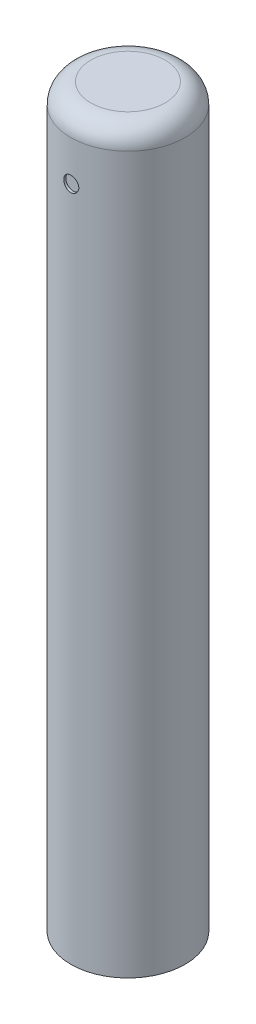
from build123d import *

# Parameters (mm, degrees)
SKETCH1_R           = 14.5
BOSS_EXTRUDE1_DEPTH = 186.69
FILLET1_R           = 5.08
SKETCH5_R           = 1.905
CUT_EXTRUDE4_DEPTH  = 0.635
SKETCH2_R           = 1.905
CUT_EXTRUDE5_DEPTH  = 0.635


with BuildPart() as part:
    # Sketch1 → Boss-Extrude1 (new body)
    with BuildSketch(Plane(origin=(0, 0, 0), x_dir=(1, 0, 0), z_dir=(0, 1, 0))):
        Circle(SKETCH1_R)
    extrude(amount=BOSS_EXTRUDE1_DEPTH)

    # Fillet1
    fillet1_edges = [part.edges().sort_by_distance(p)[0] for p in [
        (-14.5, 186.69, 0),
    ]]
    fillet(fillet1_edges, radius=FILLET1_R)

    # Sketch5 → Cut-Extrude4 (cut)
    with BuildSketch(Plane.XY.offset(-14.499999956)):
        with Locations((0, 171.45)):
            Circle(SKETCH5_R)
    extrude(amount=CUT_EXTRUDE4_DEPTH, mode=Mode.SUBTRACT)

    # Sketch2 → Cut-Extrude5 (cut)
    with BuildSketch(Plane.XY.offset(14.499999956)):
        with Locations((0, 171.45)):
            Circle(SKETCH2_R)
    extrude(amount=-CUT_EXTRUDE5_DEPTH, mode=Mode.SUBTRACT)


solid = part.part
